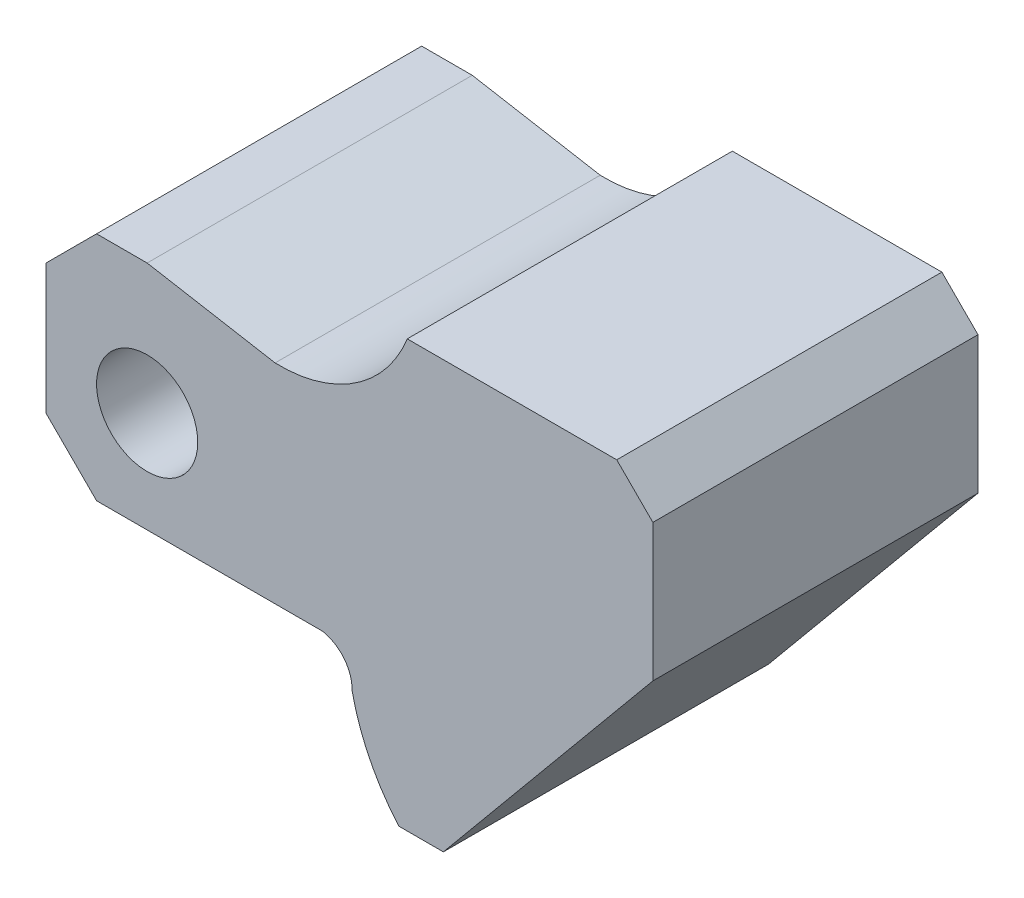
from build123d import *

# Parameters (mm, degrees)
BOSS_EXTRU_1_DEPTH      = 45
ESQUISSE2_R             = 7
ENL_V_MAT_EXTRU_1_DEPTH = 45


with BuildPart() as part:
    # Esquisse1 → Boss.-Extru.1 (new body)
    with BuildSketch(Plane.XY):
        with BuildLine():
            Line((67.055498862, 42.585779817), (96.055498862, 42.585779817))
            Line((96.055498862, 42.585779817), (101.055498862, 37.585779817))
            Line((101.055498862, 37.585779817), (101.055498862, 18.585779817))
            Line((101.055498862, 18.585779817), (72.055498862, -16.414220183))
            Line((72.055498862, -16.414220183), (65.889453705, -16.414220183))
            ThreePointArc((65.889453705, -16.414220183), (61.82352383, -10.310269713), (59.418933012, -3.381493479))
            ThreePointArc((59.418933012, -3.381493479), (58.316949941, -0.102489997), (55.350190939, 1.676434271))
            Line((55.350190939, 1.676434271), (24.055498862, 1.676434271))
            Line((24.055498862, 1.676434271), (17.055498862, 8.676434271))
            Line((17.055498862, 8.676434271), (17.055498862, 26.676434271))
            Line((17.055498862, 26.676434271), (24.055498862, 33.676434271))
            Line((24.055498862, 33.676434271), (31.055498862, 33.676434271))
            Line((31.055498862, 33.676434271), (48.765077496, 30.553757741))
            ThreePointArc((48.765077496, 30.553757741), (59.817474753, 33.670568141), (67.055498862, 42.585779817))
        make_face()
    extrude(amount=BOSS_EXTRU_1_DEPTH)

    # Esquisse2 → Enlèv. mat.-Extru.1 (cut)
    with BuildSketch(Plane.XY.offset(45)):
        with Locations((31.055498862, 15.676434271)):
            Circle(ESQUISSE2_R)
    extrude(amount=-ENL_V_MAT_EXTRU_1_DEPTH, mode=Mode.SUBTRACT)


solid = part.part
